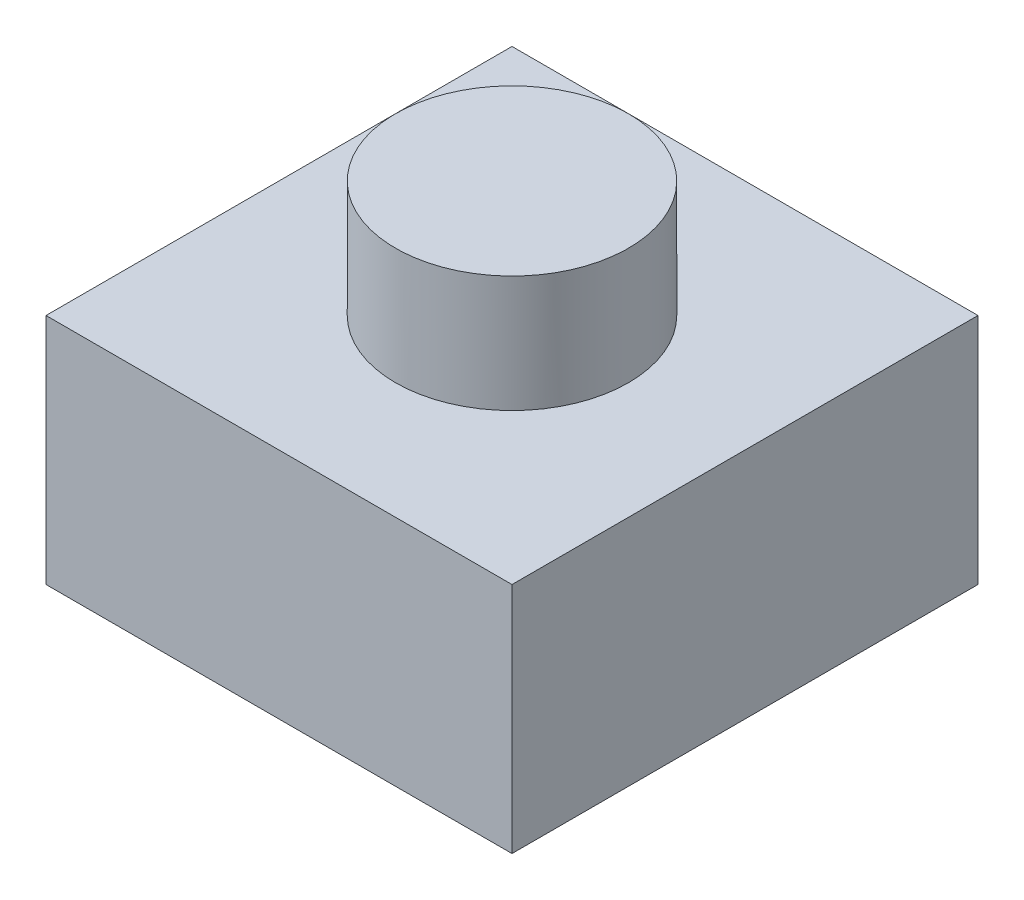
from build123d import *

# Parameters (mm, degrees)
SKETCH1_W           = 80
SKETCH1_H           = 80
SKETCH1_R           = 20
BOSS_EXTRUDE1_DEPTH = 40
SKETCH1_3_R         = 20
BOSS_EXTRUDE2_DEPTH = 60


with BuildPart() as part:
    # Sketch1 → Boss-Extrude1 (new body)
    with BuildSketch(Plane(origin=(0, 0, 0), x_dir=(1, 0, 0), z_dir=(0, 1, 0))):
        with Locations((40, 40)):
            Rectangle(SKETCH1_W, SKETCH1_H)
        with Locations((40, 40)):
            Circle(SKETCH1_R, mode=Mode.SUBTRACT)
    extrude(amount=BOSS_EXTRUDE1_DEPTH)

    # Sketch1_3 → Boss-Extrude2 (add)
    with BuildSketch(Plane(origin=(0, 0, 0), x_dir=(1, 0, 0), z_dir=(0, 1, 0))):
        with Locations((40, 40)):
            Circle(SKETCH1_3_R)
    extrude(amount=BOSS_EXTRUDE2_DEPTH)


solid = part.part
